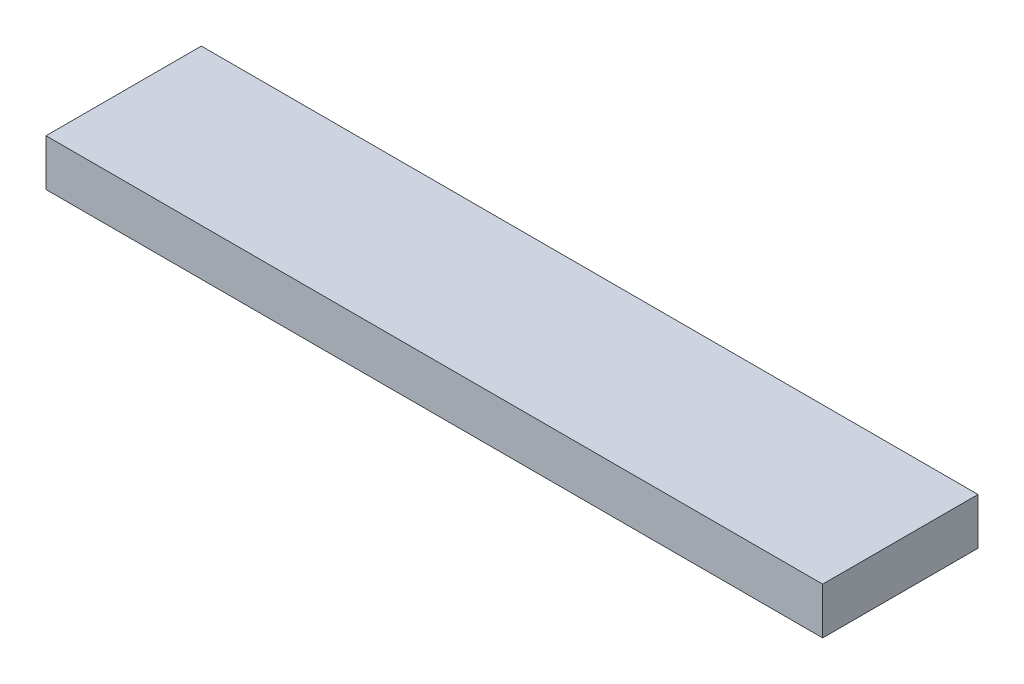
from build123d import *

# Parameters (mm, degrees)
SKETCH1_W           = 100
SKETCH1_H           = 20
BOSS_EXTRUDE1_DEPTH = 6


with BuildPart() as part:
    # Sketch1 → Boss-Extrude1 (new body)
    with BuildSketch(Plane(origin=(0, 0, 0), x_dir=(1, 0, 0), z_dir=(0, 1, 0))):
        with Locations((-14.192139738, 13.508005822)):
            Rectangle(SKETCH1_W, SKETCH1_H)
    extrude(amount=BOSS_EXTRUDE1_DEPTH)


solid = part.part
